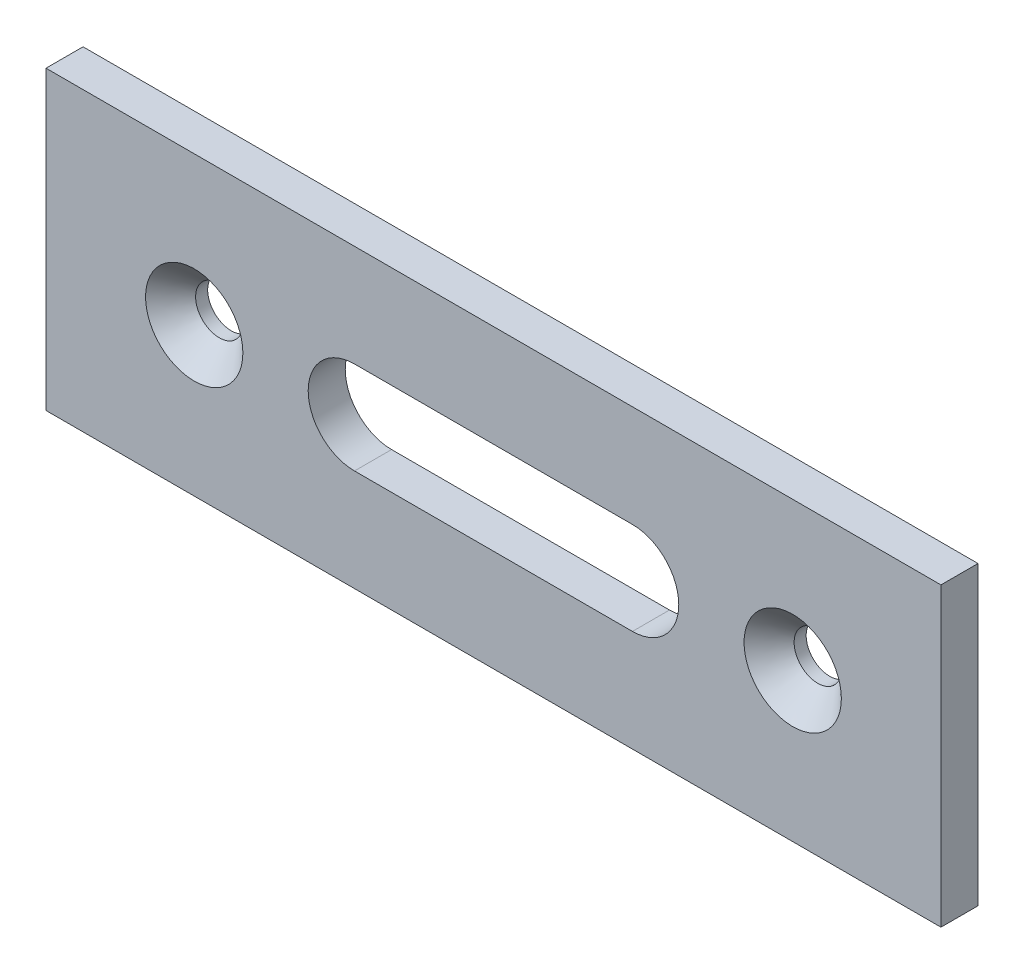
from build123d import *

# Parameters (mm, degrees)
SKETCH1_W                                  = 96.6
SKETCH1_H                                  = 32
BOSS_EXTRUDE1_DEPTH                        = 4
CUT_EXTRUDE1_DEPTH                         = 5
FRAISAGE_POUR_VIS_T_TE_FRAIS_E_BOM_2_COUNT = 2
FRAISAGE_POUR_VIS_T_TE_FRAIS_E_BOM_2_PITCH = 64.6


with BuildPart() as part:
    # Sketch1 → Boss-Extrude1 (new body)
    with BuildSketch(Plane.XY):
        with Locations((28.417538555, 0.671328671)):
            Rectangle(SKETCH1_W, SKETCH1_H)
    extrude(amount=BOSS_EXTRUDE1_DEPTH)

    # Sketch2 → Cut-Extrude1 (cut, through all)
    with BuildSketch(Plane.XY.offset(4)):
        with BuildLine():
            Line((13.417538555, 5.671328671), (43.417538555, 5.671328671))
            ThreePointArc((43.417538555, 5.671328671), (48.417538555, 0.671328671), (43.417538555, -4.328671329))
            Line((43.417538555, -4.328671329), (13.417538555, -4.328671329))
            ThreePointArc((13.417538555, -4.328671329), (8.417538555, 0.671328671), (13.417538555, 5.671328671))
        make_face()
    extrude(amount=-CUT_EXTRUDE1_DEPTH, mode=Mode.SUBTRACT)

    # Esquisse3 → Fraisage pour vis à tête fraisée bombée #51 (revolve, cut)
    with BuildSketch(Plane(origin=(-3.882461445, 0.671328671, 4), x_dir=(0, -1, 0), z_dir=(1, 0, 0))):
        Polygon((0, 0), (0, 4), (2.54999998, 4), (2.54999998, 2.700000061), (5.250000041, 0), align=None)
    fraisage_pour_vis_t_te_frais_e_bomb_e = revolve(axis=Axis((-3.882461445, 0.671328671, 10.35), (0, 0, -1)), mode=Mode.SUBTRACT)

    # Fraisage pour vis _ t_te frais_e bom 2: Fraisage pour vis à tête fraisée bombée #51 ×2
    with Locations(*[(i * FRAISAGE_POUR_VIS_T_TE_FRAIS_E_BOM_2_PITCH, 0, 0) for i in range(1, FRAISAGE_POUR_VIS_T_TE_FRAIS_E_BOM_2_COUNT)]):
        add(fraisage_pour_vis_t_te_frais_e_bomb_e, mode=Mode.SUBTRACT)


solid = part.part
